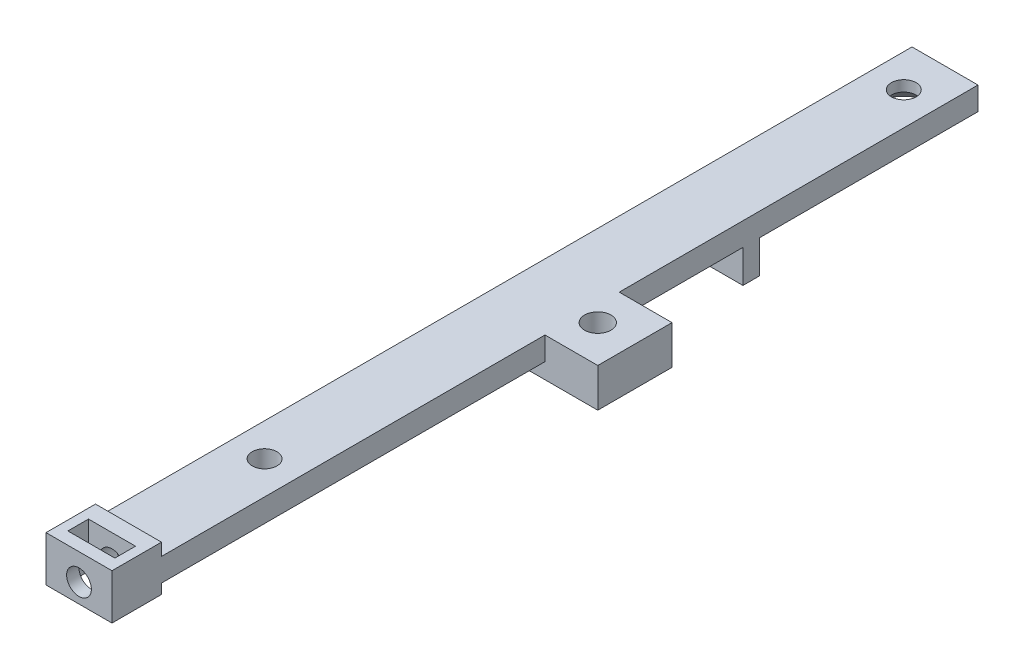
from build123d import *

# Parameters (mm, degrees)
BOSS_EXTRUDE1_DEPTH      = 2.8
CUT_EXTRUDE1_REACH       = 4.8
SKETCH3_R                = 1.5
CHAMFER1_SIZE            = 1.5
SKETCH6_W                = 8
SKETCH6_H                = 6
BOSS_EXTRUDE3_DEPTH      = 1.2
BOSS_EXTRUDE3_DEPTH_BACK = 4.3
SKETCH7_R                = 1.5
CUT_EXTRUDE3_DEPTH       = 6
SKETCH8_W                = 5.7
SKETCH8_H                = 2.5
CUT_EXTRUDE4_DEPTH       = 7
SKETCH9_W                = 14.4
SKETCH9_H                = 9
BOSS_EXTRUDE4_DEPTH      = 4.7
CUT_EXTRUDE5_REACH       = 8.2
SKETCH10_R               = 1.6
SKETCH10_R_2             = 1.5
SKETCH11_W               = 8
SKETCH11_H               = 2
BOSS_EXTRUDE5_DEPTH      = 4


with BuildPart() as part:
    # Sketch2 → Boss-Extrude1 (new body)
    with BuildSketch(Plane(origin=(0, 0, 0), x_dir=(1, 0, 0), z_dir=(0, 1, 0))):
        Polygon((0, 0), (0, 37.522747897), (0, 55), (0, 105), (4, 105), (8, 105), (8, 55), (8, 37.522747897), (8, 0), align=None)
    extrude(amount=BOSS_EXTRUDE1_DEPTH)

    # Sketch3 → Cut-Extrude1 (cut, up to next)
    with BuildSketch(Plane(origin=(0, 2.8, 0), x_dir=(1, 0, 0), z_dir=(0, 1, 0)), mode=Mode.PRIVATE) as cut_extrude1_sk1:
        with Locations(Location((4, 100, 0), (0, 0, 270))):  # turned: the seam where the file's is
            Circle(SKETCH3_R)
    cut_extrude1_tool1 = extrude(cut_extrude1_sk1.sketch, amount=-CUT_EXTRUDE1_REACH, mode=Mode.PRIVATE) & part.part
    add(cut_extrude1_tool1.solids().sort_by_distance((4, 2.8, -100))[0], mode=Mode.SUBTRACT)

    # Chamfer1
    chamfer1_edges = [part.edges().sort_by_distance(p)[0] for p in [
        (4, 0, -101.5),
    ]]
    chamfer(chamfer1_edges, length=CHAMFER1_SIZE)

    # Sketch6 → Boss-Extrude3 (add, two sides)
    with BuildSketch(Plane(origin=(0, 0, 0), x_dir=(-1, 0, 0), z_dir=(0, -1, 0))) as boss_extrude3_sk:
        with Locations((-4, 3)):
            Rectangle(SKETCH6_W, SKETCH6_H)
    extrude(amount=BOSS_EXTRUDE3_DEPTH)
    extrude(boss_extrude3_sk.sketch, amount=-BOSS_EXTRUDE3_DEPTH_BACK)

    # Sketch7 → Cut-Extrude3 (cut)
    with BuildSketch(Plane.XY):
        with Locations((4, 1.1)):
            Circle(SKETCH7_R)
    extrude(amount=-CUT_EXTRUDE3_DEPTH, mode=Mode.SUBTRACT)

    # Sketch8 → Cut-Extrude4 (cut)
    with BuildSketch(Plane(origin=(0, 4.3, 0), x_dir=(1, 0, 0), z_dir=(0, 1, 0))):
        with Locations((4, 2.75)):
            Rectangle(SKETCH8_W, SKETCH8_H)
    extrude(amount=-CUT_EXTRUDE4_DEPTH, mode=Mode.SUBTRACT)

    # Sketch9 → Boss-Extrude4 (add)
    with BuildSketch(Plane(origin=(0, 2.8, 0), x_dir=(1, 0, 0), z_dir=(0, 1, 0))):
        with Locations((7.2, 57)):
            Rectangle(SKETCH9_W, SKETCH9_H)
    extrude(amount=-BOSS_EXTRUDE4_DEPTH)

    # Sketch10 → Cut-Extrude5 (cut, up to next)
    with BuildSketch(Plane.XZ.offset(1.9), mode=Mode.PRIVATE) as cut_extrude5_sk1:
        with Locations(Location((9.9, -57, 0), (0, 0, 270))):  # turned: the seam where the file's is
            Circle(SKETCH10_R)
    cut_extrude5_tool1 = extrude(cut_extrude5_sk1.sketch, amount=-CUT_EXTRUDE5_REACH, mode=Mode.PRIVATE) & part.part
    add(cut_extrude5_tool1.solids().sort_by_distance((9.9, -1.9, -57))[0], mode=Mode.SUBTRACT)
    # Sketch10 → Cut-Extrude5 (cut, up to next)
    with BuildSketch(Plane.XZ.offset(1.9), mode=Mode.PRIVATE) as cut_extrude5_sk2:
        with Locations(Location((4, -22.5, 0), (0, 0, 270))):  # turned: the seam where the file's is
            Circle(SKETCH10_R_2)
    cut_extrude5_tool2 = extrude(cut_extrude5_sk2.sketch, amount=-CUT_EXTRUDE5_REACH, mode=Mode.PRIVATE) & part.part
    add(cut_extrude5_tool2.solids().sort_by_distance((4, -1.9, -22.5))[0], mode=Mode.SUBTRACT)

    # Sketch11 → Boss-Extrude5 (add)
    with BuildSketch(Plane.XZ):
        with Locations((4, -77.5)):
            Rectangle(SKETCH11_W, SKETCH11_H)
    extrude(amount=BOSS_EXTRUDE5_DEPTH)


solid = part.part
